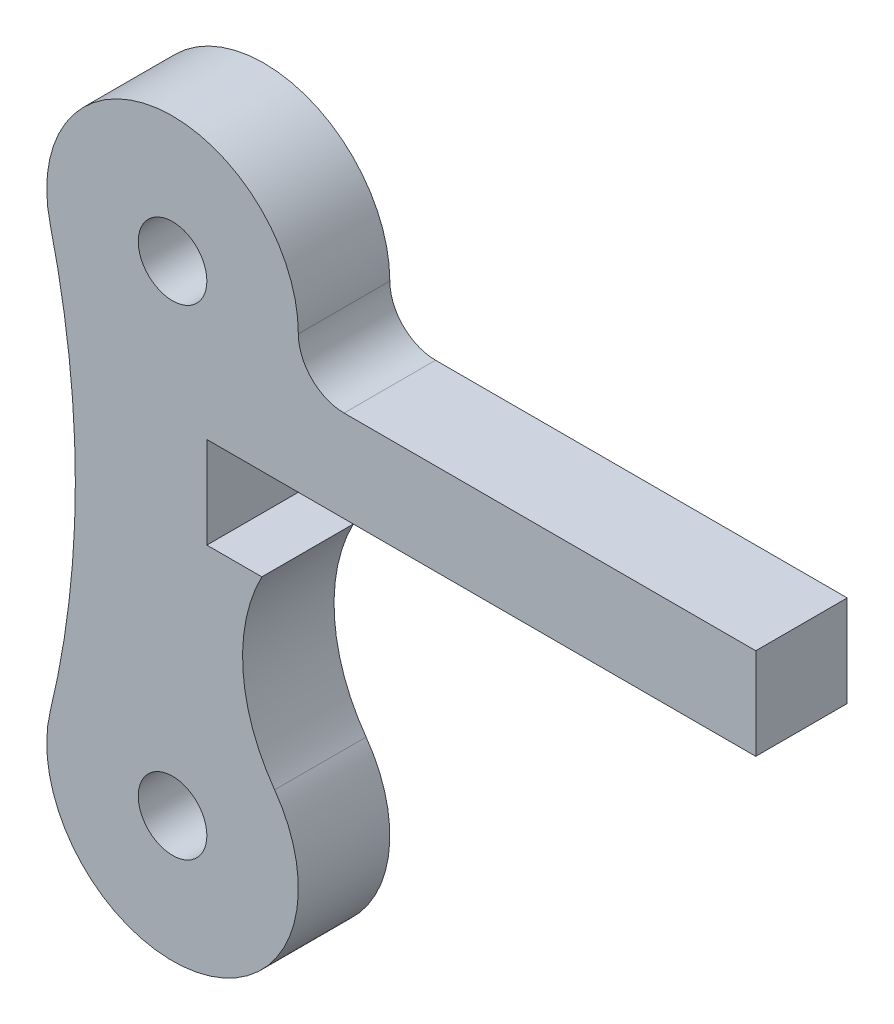
from build123d import *

# Parameters (mm, degrees)
SKETCH1_R           = 1.5
BOSS_EXTRUDE1_DEPTH = 4
SKETCH2_W           = 24
SKETCH2_H           = 4
CUT_EXTRUDE1_DEPTH  = 10


with BuildPart() as part:
    # Sketch1 → Boss-Extrude1 (new body)
    with BuildSketch(Plane.XY):
        with BuildLine():
            Line((25.5, -2), (7.5, -2))
            ThreePointArc((7.5, -2), (6.085786438, -1.414213562), (5.5, 0))
            ThreePointArc((5.5, 0), (-0.650170894, 5.461435508), (-5.34628284, -1.291224148))
            ThreePointArc((-5.34628284, -1.291224148), (-4.25, -10.5), (-5.34628284, -19.708775852))
            ThreePointArc((-5.34628284, -19.708775852), (1.057902641, -26.39729951), (4.463242224, -17.786050895))
            ThreePointArc((4.463242224, -17.786050895), (3.8789457, -10.047752676), (10.5, -6))
            Line((10.5, -6), (25.5, -6))
            Line((25.5, -6), (25.5, -2))
        make_face()
        Circle(SKETCH1_R, mode=Mode.SUBTRACT)
        with Locations((0, -21)):
            Circle(SKETCH1_R, mode=Mode.SUBTRACT)
    extrude(amount=BOSS_EXTRUDE1_DEPTH)

    # Sketch2 → Cut-Extrude1 (cut)
    with BuildSketch(Plane.XY.offset(4)):
        with Locations((13.5, -8)):
            Rectangle(SKETCH2_W, SKETCH2_H)
    extrude(amount=-CUT_EXTRUDE1_DEPTH, mode=Mode.SUBTRACT)


solid = part.part
